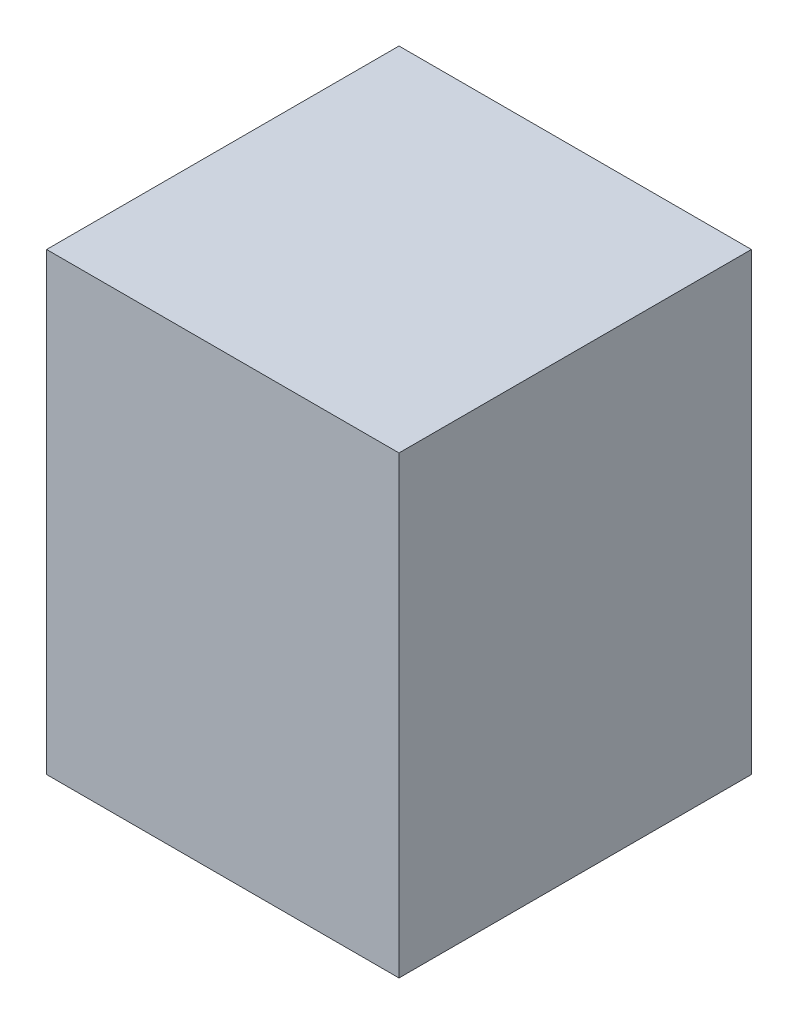
from build123d import *

# Parameters (mm, degrees)
SKETCH1_W           = 314.96
SKETCH1_H           = 314.96
SKETCH1_W_2         = 304.8
SKETCH1_H_2         = 304.8
SKETCH1_R           = 3.175
BOSS_EXTRUDE1_DEPTH = 406.4


with BuildPart() as part:
    # Sketch1 → Boss-Extrude1 (new body)
    with BuildSketch(Plane(origin=(0, 0, 0), x_dir=(1, 0, 0), z_dir=(0, 1, 0))):
        with Locations((152.4, 152.4)):
            Rectangle(SKETCH1_W, SKETCH1_H)
        with Locations((152.4, 152.4)):
            Rectangle(SKETCH1_W_2, SKETCH1_H_2, mode=Mode.SUBTRACT)
        with Locations((152.4, 152.4)):
            Rectangle(SKETCH1_W_2, SKETCH1_H_2)
        with Locations((116.2685, 152.4)):
            Circle(SKETCH1_R, mode=Mode.SUBTRACT)
        with Locations((152.4, 116.2685)):
            Circle(SKETCH1_R, mode=Mode.SUBTRACT)
        with Locations((188.5315, 152.4)):
            Circle(SKETCH1_R, mode=Mode.SUBTRACT)
        with Locations((152.4, 188.5315)):
            Circle(SKETCH1_R, mode=Mode.SUBTRACT)
        with Locations((116.2685, 152.4)):
            Circle(SKETCH1_R)
        with Locations((152.4, 116.2685)):
            Circle(SKETCH1_R)
        with Locations((188.5315, 152.4)):
            Circle(SKETCH1_R)
        with Locations((152.4, 188.5315)):
            Circle(SKETCH1_R)
    extrude(amount=BOSS_EXTRUDE1_DEPTH)


solid = part.part
